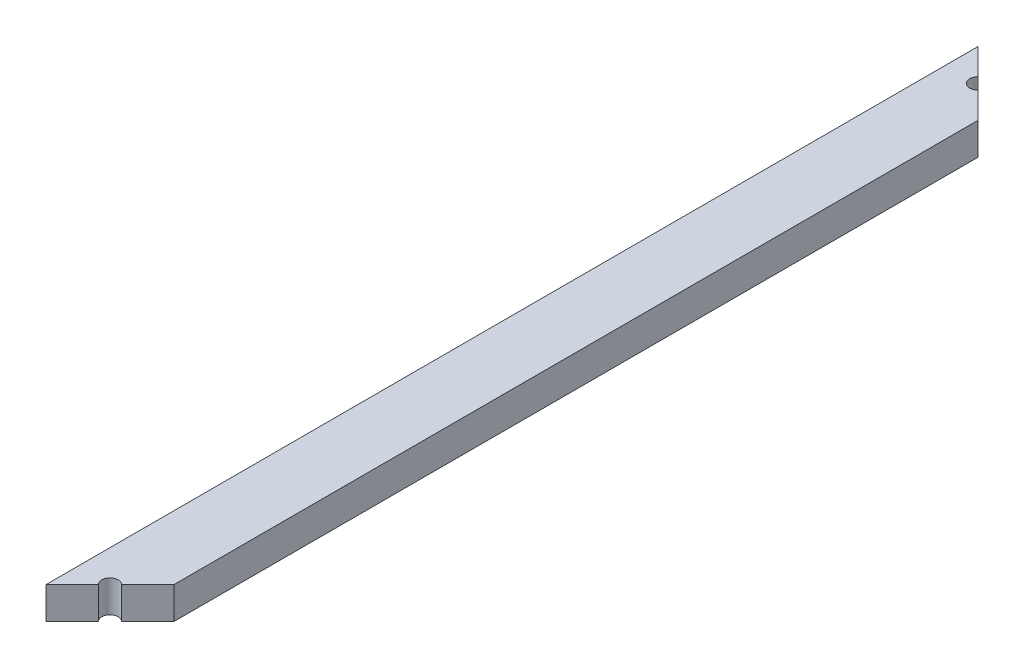
from build123d import *

# Parameters (mm, degrees)
SKETCH1_W           = 14
SKETCH1_H           = 7
BOSS_EXTRUDE1_DEPTH = 204
CUT_EXTRUDE1_DEPTH  = 8
CUT_EXTRUDE2_DEPTH  = 8


with BuildPart() as part:
    # Sketch1 → Boss-Extrude1 (new body)
    with BuildSketch(Plane.XY):
        with Locations((7, 3.5)):
            Rectangle(SKETCH1_W, SKETCH1_H)
    extrude(amount=BOSS_EXTRUDE1_DEPTH)

    # Sketch2 → Cut-Extrude1 (cut, through all)
    with BuildSketch(Plane(origin=(0, 7, 0), x_dir=(1, 0, 0), z_dir=(0, 1, 0))):
        Polygon((0, 0), (14, -14), (14, 0), align=None)
        Polygon((14, -204), (0, -204), (14, -190), align=None)
    extrude(amount=-CUT_EXTRUDE1_DEPTH, mode=Mode.SUBTRACT)

    # Sketch3 → Cut-Extrude2 (cut, through all)
    with BuildSketch(Plane(origin=(0, 7, 0), x_dir=(1, 0, 0), z_dir=(0, 1, 0))):
        with BuildLine():
            Line((8.272792206, -195.727207794), (5.727207794, -198.272792206))
            ThreePointArc((5.727207794, -198.272792206), (5.727207794, -195.727207794), (8.272792206, -195.727207794))
        make_face()
        with BuildLine():
            Line((5.727207794, -5.727207794), (8.272792206, -8.272792206))
            ThreePointArc((8.272792206, -8.272792206), (5.727207794, -8.272792206), (5.727207794, -5.727207794))
        make_face()
    extrude(amount=-CUT_EXTRUDE2_DEPTH, mode=Mode.SUBTRACT)


solid = part.part
